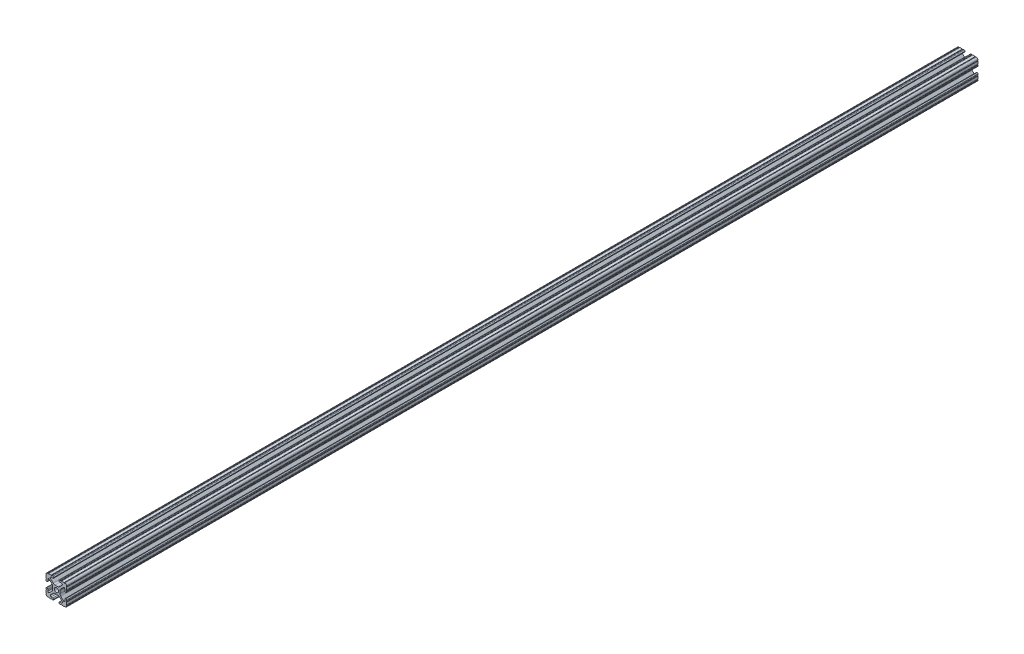
from build123d import *

# Parameters (mm, degrees)
SKETCH1_R           = 2.6035
BOSS_EXTRUDE1_DEPTH = 558.8


with BuildPart() as part:
    # Sketch1 → Boss-Extrude1 (new body, symmetric)
    with BuildSketch(Plane.XY):
        with BuildLine():
            Line((-7.179650497, -8.645192506), (-3.952270251, -5.423690499))
            ThreePointArc((-3.952270251, -5.423690499), (-2.922936451, -4.736929036), (-1.709253557, -4.4958))
            Line((-1.709253557, -4.4958), (1.709253557, -4.4958))
            ThreePointArc((1.709253557, -4.4958), (2.922936451, -4.736929036), (3.952270251, -5.423690499))
            Line((3.952270251, -5.423690499), (7.179650497, -8.645192506))
            ThreePointArc((7.179650497, -8.645192506), (7.41473083, -9.822813117), (6.416408329, -10.4902))
            Line((6.416408329, -10.4902), (4.287512407, -10.4902))
            ThreePointArc((4.287512407, -10.4902), (3.54574862, -10.79744862), (3.2385, -11.539212407))
            Line((3.2385, -11.539212407), (3.2385, -11.650987593))
            ThreePointArc((3.2385, -11.650987593), (3.54574862, -12.39275138), (4.287512407, -12.7))
            Line((4.287512407, -12.7), (5.317126718, -12.7))
            ThreePointArc((5.317126718, -12.7), (5.825126718, -12.192), (6.333126718, -12.7))
            Line((6.333126718, -12.7), (9.550443118, -12.7))
            ThreePointArc((9.550443118, -12.7), (10.058366869, -12.192000006), (10.566443095, -12.699847501))
            ThreePointArc((10.566443095, -12.699847501), (12.082537762, -12.08250727), (12.699846982, -10.566399977))
            ThreePointArc((12.699846982, -10.566399977), (12.192000006, -10.058323491), (12.7, -9.5504))
            Line((12.7, -9.5504), (12.7, -6.3330836))
            ThreePointArc((12.7, -6.3330836), (12.192, -5.8250836), (12.7, -5.3170836))
            Line((12.7, -5.3170836), (12.7, -4.287469289))
            ThreePointArc((12.7, -4.287469289), (12.39275138, -3.545705502), (11.650987593, -3.238456882))
            Line((11.650987593, -3.238456882), (11.539212407, -3.238456882))
            ThreePointArc((11.539212407, -3.238456882), (10.79744862, -3.545705502), (10.4902, -4.287469289))
            Line((10.4902, -4.287469289), (10.4902, -6.402089023))
            ThreePointArc((10.4902, -6.402089023), (9.856505071, -7.351067942), (8.737131347, -7.129408934))
            Line((8.737131347, -7.129408934), (5.441005833, -3.840816462))
            ThreePointArc((5.441005833, -3.840816462), (4.750877967, -2.809883091), (4.5085, -1.593185507))
            Line((4.5085, -1.593185507), (4.5085, 1.593185507))
            ThreePointArc((4.5085, 1.593185507), (4.750877967, 2.809883091), (5.441005833, 3.840816462))
            Line((5.441005833, 3.840816462), (8.737131347, 7.129408934))
            ThreePointArc((8.737131347, 7.129408934), (9.856505071, 7.351067942), (10.4902, 6.402089023))
            Line((10.4902, 6.402089023), (10.4902, 4.287469289))
            ThreePointArc((10.4902, 4.287469289), (10.79744862, 3.545705502), (11.539212407, 3.238456882))
            Line((11.539212407, 3.238456882), (11.650987593, 3.238456882))
            ThreePointArc((11.650987593, 3.238456882), (12.39275138, 3.545705502), (12.7, 4.287469289))
            Line((12.7, 4.287469289), (12.7, 5.3170836))
            ThreePointArc((12.7, 5.3170836), (12.192, 5.8250836), (12.7, 6.3330836))
            Line((12.7, 6.3330836), (12.7, 9.5504))
            ThreePointArc((12.7, 9.5504), (12.192000006, 10.058323491), (12.699846982, 10.566399977))
            ThreePointArc((12.699846982, 10.566399977), (12.082537762, 12.08250727), (10.566443095, 12.699847501))
            ThreePointArc((10.566443095, 12.699847501), (10.058366869, 12.192000006), (9.550443118, 12.7))
            Line((9.550443118, 12.7), (6.333126718, 12.7))
            ThreePointArc((6.333126718, 12.7), (5.825126718, 12.192), (5.317126718, 12.7))
            Line((5.317126718, 12.7), (4.287512407, 12.7))
            ThreePointArc((4.287512407, 12.7), (3.54574862, 12.39275138), (3.2385, 11.650987593))
            Line((3.2385, 11.650987593), (3.2385, 11.539212407))
            ThreePointArc((3.2385, 11.539212407), (3.54574862, 10.79744862), (4.287512407, 10.4902))
            Line((4.287512407, 10.4902), (6.476788598, 10.4902))
            ThreePointArc((6.476788598, 10.4902), (7.432222385, 9.85140422), (7.207036008, 8.724370562))
            Line((7.207036008, 8.724370562), (3.898272566, 5.423169045))
            ThreePointArc((3.898272566, 5.423169045), (2.869120213, 4.736787962), (1.655778399, 4.4958))
            Line((1.655778399, 4.4958), (-1.655778399, 4.4958))
            ThreePointArc((-1.655778399, 4.4958), (-2.869120213, 4.736787962), (-3.898272566, 5.423169045))
            Line((-3.898272566, 5.423169045), (-7.207036008, 8.724370562))
            ThreePointArc((-7.207036008, 8.724370562), (-7.432222385, 9.85140422), (-6.476788598, 10.4902))
            Line((-6.476788598, 10.4902), (-4.287512407, 10.4902))
            ThreePointArc((-4.287512407, 10.4902), (-3.54574862, 10.79744862), (-3.2385, 11.539212407))
            Line((-3.2385, 11.539212407), (-3.2385, 11.650987593))
            ThreePointArc((-3.2385, 11.650987593), (-3.54574862, 12.39275138), (-4.287512407, 12.7))
            Line((-4.287512407, 12.7), (-5.317126718, 12.7))
            ThreePointArc((-5.317126718, 12.7), (-5.825126718, 12.192), (-6.333126718, 12.7))
            Line((-6.333126718, 12.7), (-9.550443118, 12.7))
            ThreePointArc((-9.550443118, 12.7), (-10.058366869, 12.192000006), (-10.566443095, 12.699847501))
            ThreePointArc((-10.566443095, 12.699847501), (-12.082537762, 12.08250727), (-12.699846982, 10.566399977))
            ThreePointArc((-12.699846982, 10.566399977), (-12.192000006, 10.058323491), (-12.7, 9.5504))
            Line((-12.7, 9.5504), (-12.7, 6.3330836))
            ThreePointArc((-12.7, 6.3330836), (-12.192, 5.8250836), (-12.7, 5.3170836))
            Line((-12.7, 5.3170836), (-12.7, 4.287469289))
            ThreePointArc((-12.7, 4.287469289), (-12.39275138, 3.545705502), (-11.650987593, 3.238456882))
            Line((-11.650987593, 3.238456882), (-11.539212407, 3.238456882))
            ThreePointArc((-11.539212407, 3.238456882), (-10.79744862, 3.545705502), (-10.4902, 4.287469289))
            Line((-10.4902, 4.287469289), (-10.4902, 6.402089023))
            ThreePointArc((-10.4902, 6.402089023), (-9.856505071, 7.351067942), (-8.737131347, 7.129408934))
            Line((-8.737131347, 7.129408934), (-5.441005833, 3.840816462))
            ThreePointArc((-5.441005833, 3.840816462), (-4.750877967, 2.809883091), (-4.5085, 1.593185507))
            Line((-4.5085, 1.593185507), (-4.5085, -1.593185507))
            ThreePointArc((-4.5085, -1.593185507), (-4.750877967, -2.809883091), (-5.441005833, -3.840816462))
            Line((-5.441005833, -3.840816462), (-8.737131347, -7.129408934))
            ThreePointArc((-8.737131347, -7.129408934), (-9.856505071, -7.351067942), (-10.4902, -6.402089023))
            Line((-10.4902, -6.402089023), (-10.4902, -4.287469289))
            ThreePointArc((-10.4902, -4.287469289), (-10.79744862, -3.545705502), (-11.539212407, -3.238456882))
            Line((-11.539212407, -3.238456882), (-11.650987593, -3.238456882))
            ThreePointArc((-11.650987593, -3.238456882), (-12.39275138, -3.545705502), (-12.7, -4.287469289))
            Line((-12.7, -4.287469289), (-12.7, -5.3170836))
            ThreePointArc((-12.7, -5.3170836), (-12.192, -5.8250836), (-12.7, -6.3330836))
            Line((-12.7, -6.3330836), (-12.7, -9.5504))
            ThreePointArc((-12.7, -9.5504), (-12.192000006, -10.058323491), (-12.699846982, -10.566399977))
            ThreePointArc((-12.699846982, -10.566399977), (-12.082537762, -12.08250727), (-10.566443095, -12.699847501))
            ThreePointArc((-10.566443095, -12.699847501), (-10.058366869, -12.192000006), (-9.550443118, -12.7))
            Line((-9.550443118, -12.7), (-6.333126718, -12.7))
            ThreePointArc((-6.333126718, -12.7), (-5.825126718, -12.192), (-5.317126718, -12.7))
            Line((-5.317126718, -12.7), (-4.287512407, -12.7))
            ThreePointArc((-4.287512407, -12.7), (-3.54574862, -12.39275138), (-3.2385, -11.650987593))
            Line((-3.2385, -11.650987593), (-3.2385, -11.539212407))
            ThreePointArc((-3.2385, -11.539212407), (-3.54574862, -10.79744862), (-4.287512407, -10.4902))
            Line((-4.287512407, -10.4902), (-6.416408329, -10.4902))
            ThreePointArc((-6.416408329, -10.4902), (-7.41473083, -9.822813117), (-7.179650497, -8.645192506))
        make_face()
        Circle(SKETCH1_R, mode=Mode.SUBTRACT)
    extrude(amount=BOSS_EXTRUDE1_DEPTH, both=True)


solid = part.part
